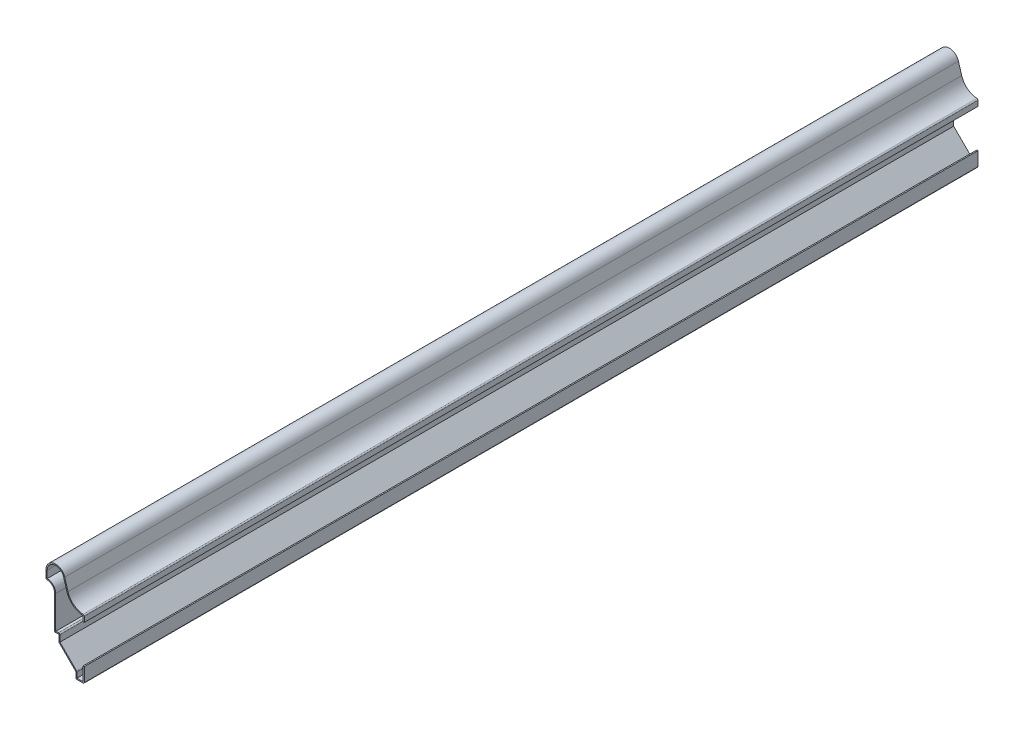
from build123d import *

# Parameters (mm, degrees)
EXTRUDE_THIN1_DEPTH = 666.75
FILLET1_R           = 0.889


with BuildPart() as part:
    # Sketch1 → Extrude-Thin1 (new body)
    with BuildSketch(Plane.XY):
        with BuildLine():
            Line((0, 11.1125), (0, 0))
            Line((0, 0), (-6.35, 0))
            Line((-6.35, 0), (-6.35, 4.7625))
            Line((-6.35, 4.7625), (-19.05, 17.4625))
            Line((-19.05, 17.4625), (-19.05, 22.621875))
            Line((-19.05, 22.621875), (-22.225, 22.225))
            Line((-22.225, 22.225), (-22.225, 47.681988686))
            ThreePointArc((-22.225, 47.681988686), (-24.143830542, 51.882118892), (-28.575, 53.18125))
            Line((-28.575, 53.18125), (-28.575, 59.53125))
            ThreePointArc((-28.575, 59.53125), (-22.468372416, 66.599314881), (-14.588636772, 61.583519054))
            Line((-14.588636772, 61.583519054), (-12.164645739, 53.501521681))
            ThreePointArc((-12.164645739, 53.501521681), (-7.581369446, 46.96114151), (0, 44.45))
            Line((0, 44.45), (0, 39.6875))
            Line((0, 39.6875), (-0.889, 39.6875))
            Line((-0.889, 39.6875), (-0.889, 43.59011062))
            ThreePointArc((-0.889, 43.59011062), (-8.464520872, 46.519251795), (-13.016170941, 53.246128199))
            Line((-13.016170941, 53.246128199), (-15.440161973, 61.328125572))
            ThreePointArc((-15.440161973, 61.328125572), (-22.339308293, 65.719733473), (-27.686, 59.53125))
            Line((-27.686, 59.53125), (-27.686, 54.12653483))
            ThreePointArc((-27.686, 54.12653483), (-23.190217566, 52.20566736), (-21.336, 47.681988686))
            Line((-21.336, 47.681988686), (-21.336, 23.232043392))
            Line((-21.336, 23.232043392), (-18.161, 23.628918392))
            Line((-18.161, 23.628918392), (-18.161, 17.830735857))
            Line((-18.161, 17.830735857), (-5.461, 5.130735857))
            Line((-5.461, 5.130735857), (-5.461, 0.889))
            Line((-5.461, 0.889), (-0.889, 0.889))
            Line((-0.889, 0.889), (-0.889, 11.1125))
            Line((-0.889, 11.1125), (0, 11.1125))
        make_face()
    extrude(amount=-EXTRUDE_THIN1_DEPTH)

    # Fillet1
    fillet1_edges = [part.edges().sort_by_distance(p)[0] for p in [
        (-18.161, 23.628918392, -333.375),
        (-5.461, 5.130735857, -333.375),
        (0, 0, -333.375),
        (-6.35, 0, -333.375),
        (-19.05, 17.4625, -333.375),
        (-22.225, 22.225, -333.375),
        (-28.575, 53.18125, -333.375),
        (0, 44.45, -333.375),
    ]]
    fillet(fillet1_edges, radius=FILLET1_R)


solid = part.part
